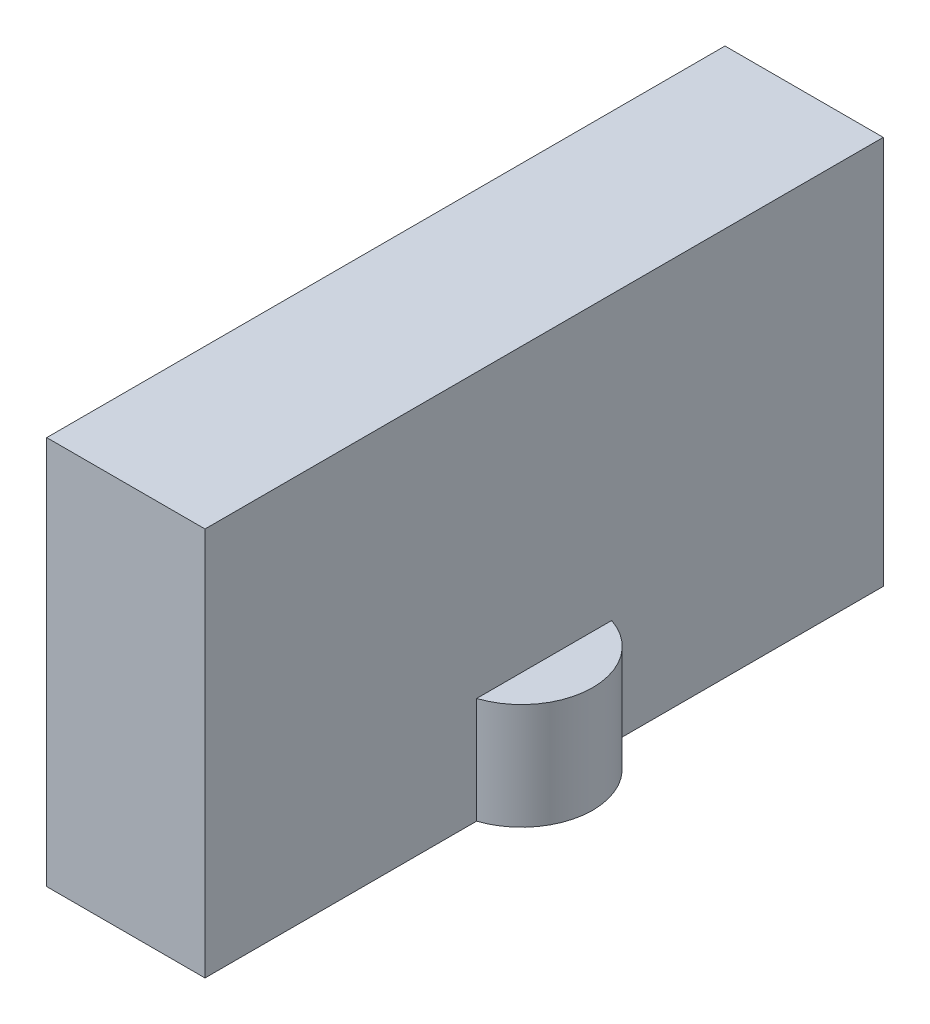
from build123d import *

# Parameters (mm, degrees)
SKETCH1_R                = 31.5
BOSS_EXTRUDE1_DEPTH      = 170
BOSS_EXTRUDE2_DEPTH      = 125
BOSS_EXTRUDE2_DEPTH_BACK = 130
SKETCH2_W                = 70
SKETCH2_H                = 300
SKETCH2_2_W              = 70
SKETCH2_2_H              = 300
BOSS_EXTRUDE3_DEPTH      = 10
SKETCH4_W                = 315.689390272
SKETCH4_H                = 433.788608214
CUT_EXTRUDE2_DEPTH       = 123


with BuildPart() as part:
    # Sketch1 → Boss-Extrude1 (new body)
    with BuildSketch(Plane(origin=(0, 0, 0), x_dir=(1, 0, 0), z_dir=(0, 1, 0))):
        Circle(SKETCH1_R)
    extrude(amount=BOSS_EXTRUDE1_DEPTH)

    # Sketch2 → Boss-Extrude2 (add, two sides: drawn at the far end of the back side and taken through both)
    with BuildSketch(Plane(origin=(0, 170, 0), x_dir=(1, 0, 0), z_dir=(0, 1, 0)).offset(-BOSS_EXTRUDE2_DEPTH_BACK)):
        with Locations((-25, 0)):
            Rectangle(SKETCH2_W, SKETCH2_H)
    extrude(amount=BOSS_EXTRUDE2_DEPTH + BOSS_EXTRUDE2_DEPTH_BACK)

    # Sketch2_2 → Boss-Extrude3 (add)
    with BuildSketch(Plane(origin=(0, 170, 0), x_dir=(1, 0, 0), z_dir=(0, 1, 0))):
        with Locations((-25, 0)):
            Rectangle(SKETCH2_2_W, SKETCH2_2_H)
    extrude(amount=BOSS_EXTRUDE3_DEPTH)

    # Sketch4 → Cut-Extrude2 (cut)
    with BuildSketch(Plane.XZ):
        Rectangle(SKETCH4_W, SKETCH4_H)
    extrude(amount=-CUT_EXTRUDE2_DEPTH, mode=Mode.SUBTRACT)


solid = part.part
